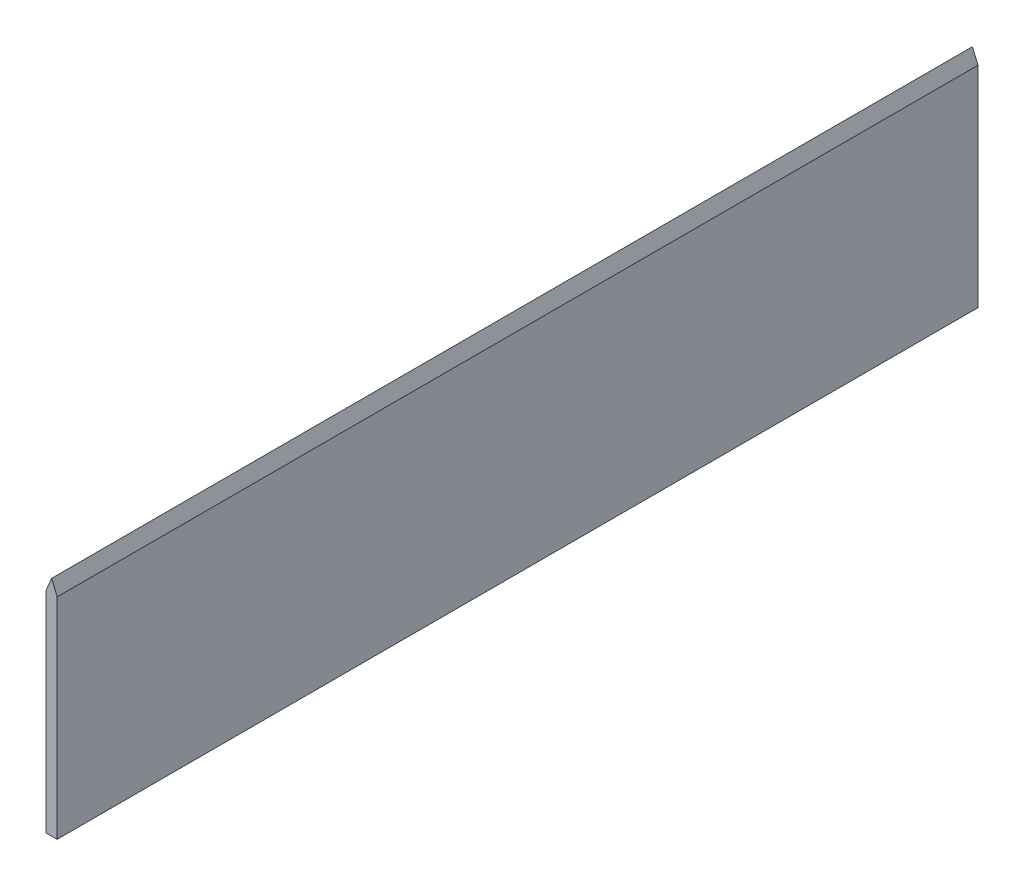
from build123d import *

# Parameters (mm, degrees)
SKETCH1_W           = 2
SKETCH1_H           = 40
BOSS_EXTRUDE1_DEPTH = 165
CUT_EXTRUDE1_DEPTH  = 165
CUT_EXTRUDE2_DEPTH  = 165


with BuildPart() as part:
    # Sketch1 → Boss-Extrude1 (new body)
    with BuildSketch(Plane.XY):
        with Locations((-1, -17.620909594)):
            Rectangle(SKETCH1_W, SKETCH1_H)
    extrude(amount=BOSS_EXTRUDE1_DEPTH)

    # Sketch2 → Cut-Extrude1 (cut)
    with BuildSketch(Plane.XY.offset(165)):
        Polygon((0, 2.379090406), (-1, 2.379090406), (0, 0), align=None)
    extrude(amount=-CUT_EXTRUDE1_DEPTH, mode=Mode.SUBTRACT)

    # Sketch3 → Cut-Extrude2 (cut)
    with BuildSketch(Plane.XY.offset(165)):
        Polygon((-1, 2.379090406), (-2, 2.379090406), (-2, 0), align=None)
    extrude(amount=-CUT_EXTRUDE2_DEPTH, mode=Mode.SUBTRACT)


solid = part.part
